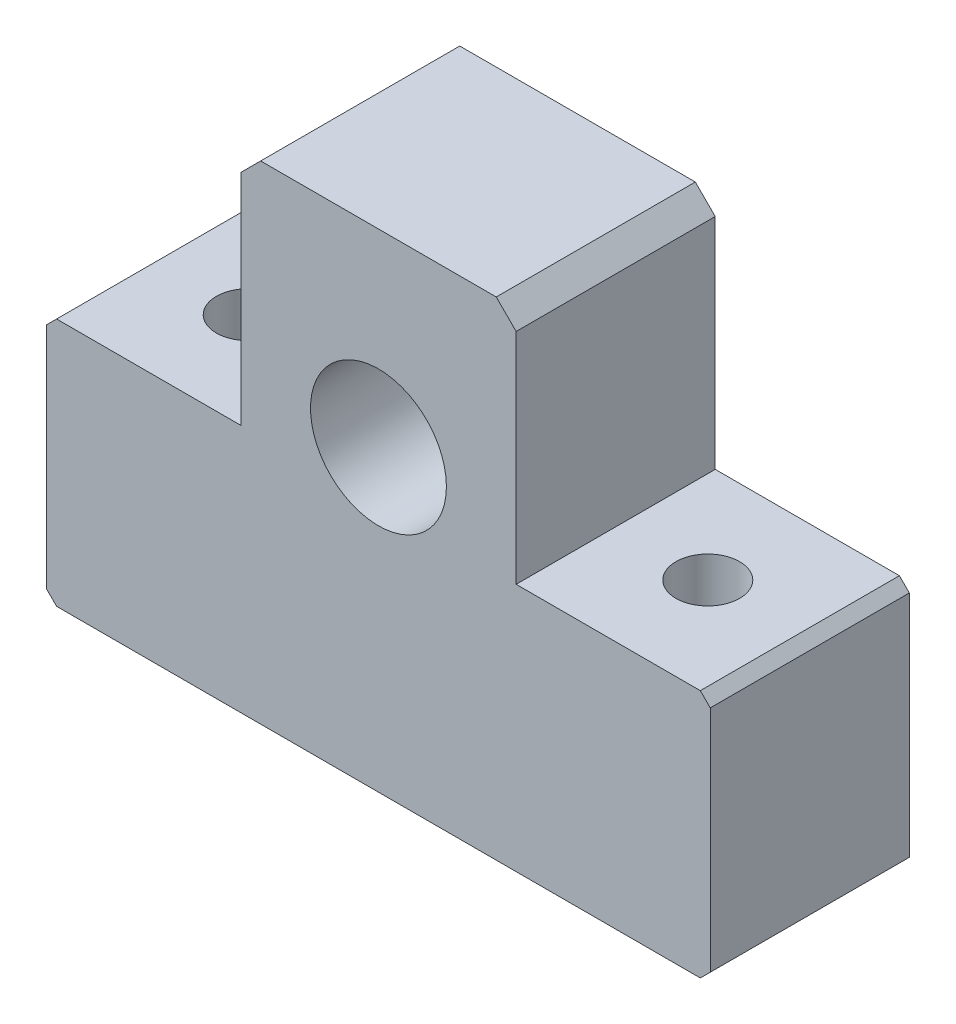
from build123d import *

# Parameters (mm, degrees)
SKETCH6_R           = 51.2
BOSS_EXTRUDE4_DEPTH = 150
SKETCH7_R           = 24
CUT_EXTRUDE1_DEPTH  = 188.5


with BuildPart() as part:
    # Sketch6 → Boss-Extrude4 (new body)
    with BuildSketch(Plane.XY):
        Polygon((-250, -3.75), (-242.5, 3.75), (-103.75, 3.75), (-103.75, 168.75), (-88.75, 183.75), (88.75, 183.75), (103.75, 168.75), (103.75, 3.75), (242.5, 3.75), (250, -3.75), (250, -176.25), (242.5, -183.75), (-242.5, -183.75), (-250, -176.25), align=None)
        with Locations((0, 41.25)):
            Circle(SKETCH6_R, mode=Mode.SUBTRACT)
    extrude(amount=BOSS_EXTRUDE4_DEPTH)

    # Sketch7 → Cut-Extrude1 (cut, through all)
    with BuildSketch(Plane(origin=(0, 3.75, 0), x_dir=(1, 0, 0), z_dir=(0, 1, 0))):
        with Locations((-173.125, -75)):
            Circle(SKETCH7_R)
    cut_extrude1 = extrude(amount=-CUT_EXTRUDE1_DEPTH, mode=Mode.SUBTRACT)

    # Mirror1: Cut-Extrude1 across plane
    add(cut_extrude1.mirror(Plane(origin=(0, 0, 0), x_dir=(0, 0, 1), z_dir=(1, 0, 0))), mode=Mode.SUBTRACT)


solid = part.part
